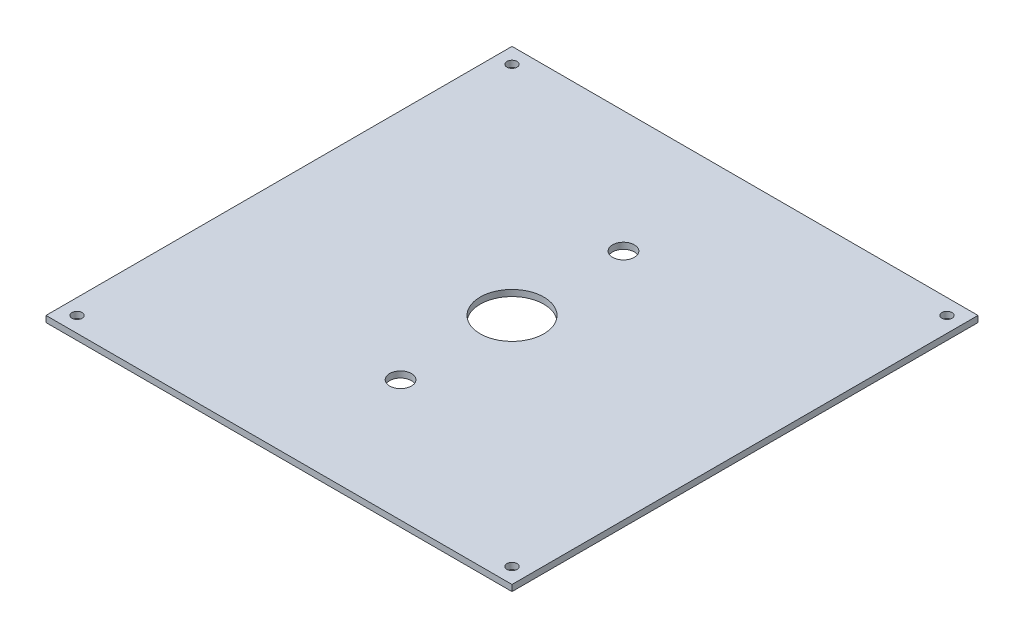
from build123d import *

# Parameters (mm, degrees)
SKETCH1_W           = 300
SKETCH1_H           = 300
BOSS_EXTRUDE1_DEPTH = 4
CUT_EXTRUDE1_REACH  = 6
SKETCH2_R           = 3.25
CUT_EXTRUDE2_REACH  = 6
SKETCH3_R           = 20.5
CUT_EXTRUDE3_REACH  = 6
SKETCH4_R           = 7


with BuildPart() as part:
    # Sketch1 → Boss-Extrude1 (new body)
    with BuildSketch(Plane(origin=(0, 0, 0), x_dir=(1, 0, 0), z_dir=(0, 1, 0))):
        Rectangle(SKETCH1_W, SKETCH1_H)
    extrude(amount=BOSS_EXTRUDE1_DEPTH)

    # Sketch2 → Cut-Extrude1 (cut, up to next)
    with BuildSketch(Plane(origin=(0, 4, 0), x_dir=(1, 0, 0), z_dir=(0, 1, 0)), mode=Mode.PRIVATE) as cut_extrude1_sk1:
        with Locations((-140, 140)):
            Circle(SKETCH2_R)
    cut_extrude1_tool1 = extrude(cut_extrude1_sk1.sketch, amount=-CUT_EXTRUDE1_REACH, mode=Mode.PRIVATE) & part.part
    add(cut_extrude1_tool1.solids().sort_by_distance((-140, 4, -140))[0], mode=Mode.SUBTRACT)
    # Sketch2 → Cut-Extrude1 (cut, up to next)
    with BuildSketch(Plane(origin=(0, 4, 0), x_dir=(1, 0, 0), z_dir=(0, 1, 0)), mode=Mode.PRIVATE) as cut_extrude1_sk2:
        with Locations((140, 140)):
            Circle(SKETCH2_R)
    cut_extrude1_tool2 = extrude(cut_extrude1_sk2.sketch, amount=-CUT_EXTRUDE1_REACH, mode=Mode.PRIVATE) & part.part
    add(cut_extrude1_tool2.solids().sort_by_distance((140, 4, -140))[0], mode=Mode.SUBTRACT)
    # Sketch2 → Cut-Extrude1 (cut, up to next)
    with BuildSketch(Plane(origin=(0, 4, 0), x_dir=(1, 0, 0), z_dir=(0, 1, 0)), mode=Mode.PRIVATE) as cut_extrude1_sk3:
        with Locations((140, -140)):
            Circle(SKETCH2_R)
    cut_extrude1_tool3 = extrude(cut_extrude1_sk3.sketch, amount=-CUT_EXTRUDE1_REACH, mode=Mode.PRIVATE) & part.part
    add(cut_extrude1_tool3.solids().sort_by_distance((140, 4, 140))[0], mode=Mode.SUBTRACT)
    # Sketch2 → Cut-Extrude1 (cut, up to next)
    with BuildSketch(Plane(origin=(0, 4, 0), x_dir=(1, 0, 0), z_dir=(0, 1, 0)), mode=Mode.PRIVATE) as cut_extrude1_sk4:
        with Locations((-140, -140)):
            Circle(SKETCH2_R)
    cut_extrude1_tool4 = extrude(cut_extrude1_sk4.sketch, amount=-CUT_EXTRUDE1_REACH, mode=Mode.PRIVATE) & part.part
    add(cut_extrude1_tool4.solids().sort_by_distance((-140, 4, 140))[0], mode=Mode.SUBTRACT)

    # Sketch3 → Cut-Extrude2 (cut, up to next)
    with BuildSketch(Plane(origin=(0, 4, 0), x_dir=(1, 0, 0), z_dir=(0, 1, 0)), mode=Mode.PRIVATE) as cut_extrude2_sk1:
        Circle(SKETCH3_R)
    cut_extrude2_tool1 = extrude(cut_extrude2_sk1.sketch, amount=-CUT_EXTRUDE2_REACH, mode=Mode.PRIVATE) & part.part
    add(cut_extrude2_tool1.solids().sort_by_distance((0, 4, 0))[0], mode=Mode.SUBTRACT)

    # Sketch4 → Cut-Extrude3 (cut, up to next)
    with BuildSketch(Plane(origin=(0, 4, 0), x_dir=(1, 0, 0), z_dir=(0, 1, 0)), mode=Mode.PRIVATE) as cut_extrude3_sk1:
        with Locations((0, 71.75)):
            Circle(SKETCH4_R)
    cut_extrude3_tool1 = extrude(cut_extrude3_sk1.sketch, amount=-CUT_EXTRUDE3_REACH, mode=Mode.PRIVATE) & part.part
    add(cut_extrude3_tool1.solids().sort_by_distance((0, 4, -71.75))[0], mode=Mode.SUBTRACT)
    # Sketch4 → Cut-Extrude3 (cut, up to next)
    with BuildSketch(Plane(origin=(0, 4, 0), x_dir=(1, 0, 0), z_dir=(0, 1, 0)), mode=Mode.PRIVATE) as cut_extrude3_sk2:
        with Locations((0, -71.75)):
            Circle(SKETCH4_R)
    cut_extrude3_tool2 = extrude(cut_extrude3_sk2.sketch, amount=-CUT_EXTRUDE3_REACH, mode=Mode.PRIVATE) & part.part
    add(cut_extrude3_tool2.solids().sort_by_distance((0, 4, 71.75))[0], mode=Mode.SUBTRACT)


solid = part.part
